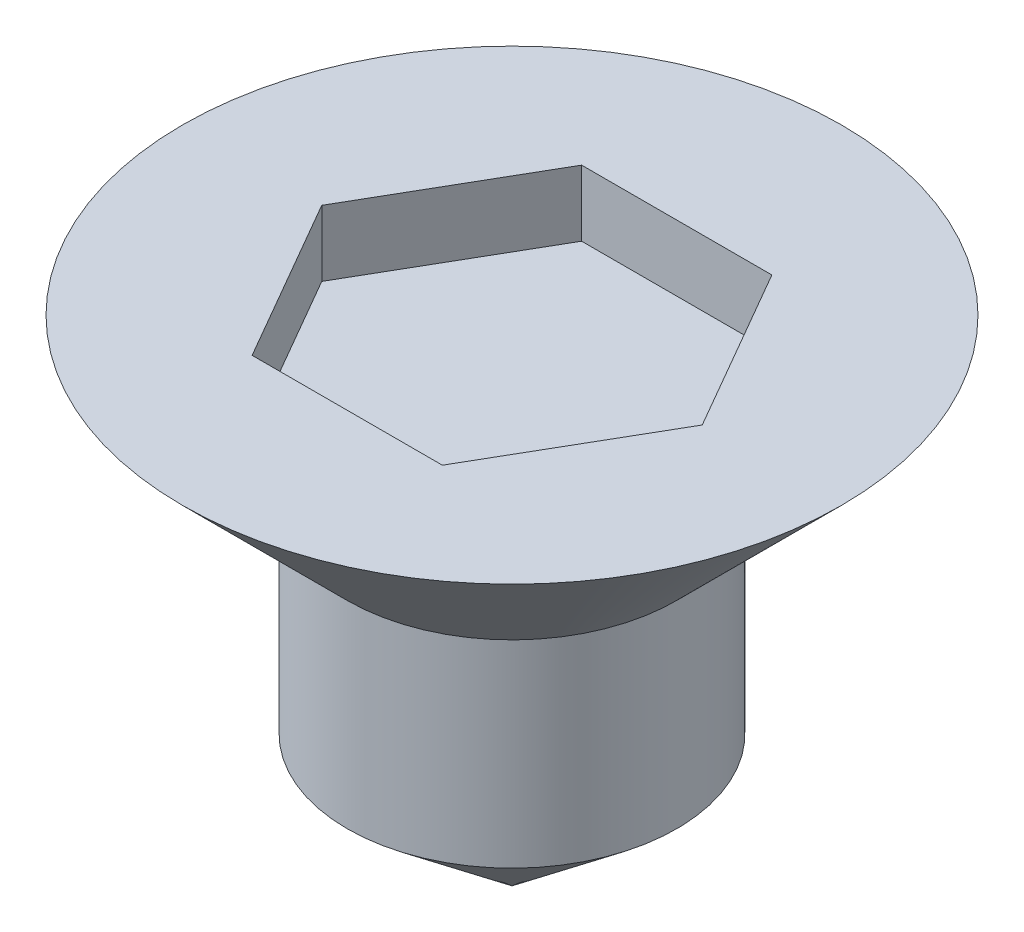
from build123d import *

# Parameters (mm, degrees)
CROQUIS1_R              = 1.25
SALIENTE_EXTRUIR1_DEPTH = 1.5
CORTAR_EXTRUIR1_DEPTH   = 0.5


with BuildPart() as part:
    # Croquis1 → Saliente-Extruir1 (new body)
    with BuildSketch(Plane(origin=(0, 0, 0), x_dir=(1, 0, 0), z_dir=(0, 1, 0))):
        Circle(CROQUIS1_R)
    extrude(amount=SALIENTE_EXTRUIR1_DEPTH)

    # Croquis2 one side → Revolución1 (revolve)
    with BuildSketch(Plane(origin=(0, 0, 0), x_dir=(0, 0, -1), z_dir=(1, 0, 0))):
        Polygon((0, 2.75), (0, 1.5), (1.25, 1.5), (2.5, 2.75), align=None)
    revolve(axis=Axis((0, 2.75, 0), (0, -1, 0)))

    # Croquis3 → Cortar-Extruir1 (cut)
    with BuildSketch(Plane(origin=(0, 2.75, 0), x_dir=(1, 0, 0), z_dir=(0, 1, 0))):
        Polygon((1.443375673, 0), (0.721687836, 1.25), (-0.721687836, 1.25), (-1.443375673, 0), (-0.721687836, -1.25), (0.721687836, -1.25), align=None)
    extrude(amount=-CORTAR_EXTRUIR1_DEPTH, mode=Mode.SUBTRACT)

    # Croquis4 one side → Revolución2 (revolve)
    with BuildSketch(Plane.XY):
        Polygon((0, 0), (0, -1), (1.25, 0), align=None)
    revolve(axis=Axis((0, 0, 0), (0, -1, 0)))


solid = part.part
